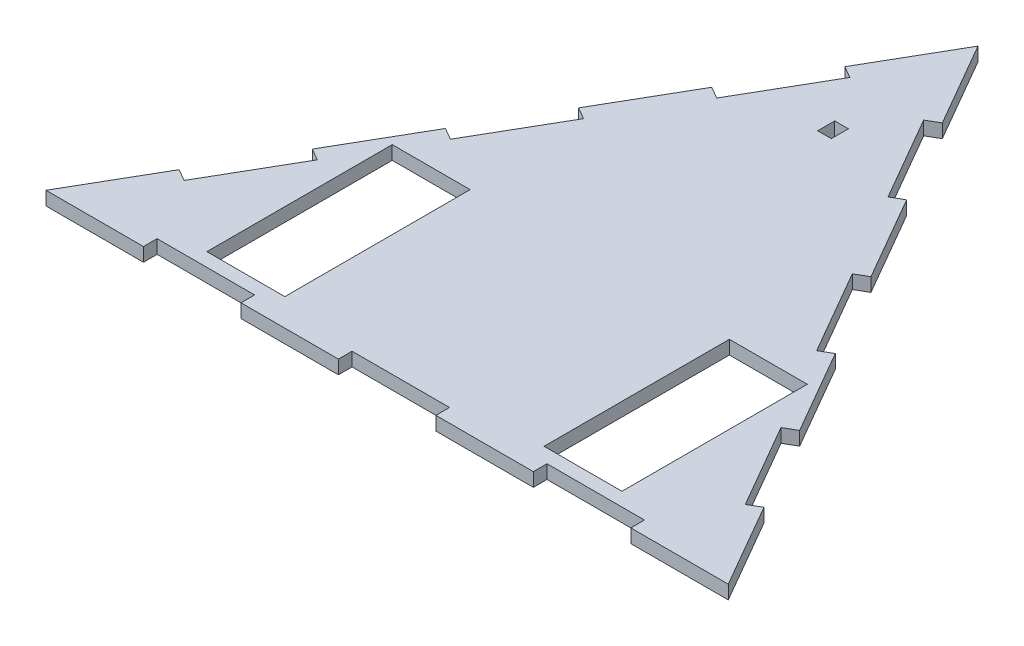
from build123d import *

# Parameters (mm, degrees)
BOSS_EXTRUDE1_DEPTH = 5.08
SKETCH4_W           = 29
SKETCH4_H           = 69
CUT_EXTRUDE1_DEPTH  = 5.08
SKETCH8_W           = 36.285714285
SKETCH8_H           = 5.08
SKETCH8_W_2         = 36.285714286
CUT_EXTRUDE2_DEPTH  = 5.08
SKETCH9_W           = 36.285714285
SKETCH9_H           = 5.08
SKETCH9_W_2         = 36.285714286
CUT_EXTRUDE3_DEPTH  = 5.08
SKETCH10_W          = 36.285714285
SKETCH10_H          = 5.08
SKETCH10_W_2        = 36.285714286
CUT_EXTRUDE4_DEPTH  = 5.08
SKETCH12_W          = 5.08
SKETCH12_H          = 6.35
CUT_EXTRUDE6_DEPTH  = 5.08


with BuildPart() as part:
    # Sketch1 → Boss-Extrude1 (new body)
    with BuildSketch(Plane(origin=(0, 0, 0), x_dir=(1, 0, 0), z_dir=(0, 1, 0))):
        Polygon((0, 0), (-254, 0), (-127, 219.970452561), align=None)
    extrude(amount=BOSS_EXTRUDE1_DEPTH)

    # Sketch4 → Cut-Extrude1 (cut)
    with BuildSketch(Plane(origin=(0, 5.08, 0), x_dir=(1, 0, 0), z_dir=(0, 1, 0))):
        with Locations((-189.76, 44.66)):
            Rectangle(SKETCH4_W, SKETCH4_H)
        with Locations((-64.24, 44.66)):
            Rectangle(SKETCH4_W, SKETCH4_H)
    extrude(amount=-CUT_EXTRUDE1_DEPTH, mode=Mode.SUBTRACT)

    # Sketch8 → Cut-Extrude2 (cut)
    with BuildSketch(Plane(origin=(-190.5, 0, -109.985226281), x_dir=(-0.5, 0, 0.866025404), z_dir=(-0.866025404, 0, -0.5))):
        with Locations((-72.571428572, 2.54)):
            Rectangle(SKETCH8_W, SKETCH8_H)
        with Locations((0, 2.54)):
            Rectangle(SKETCH8_W_2, SKETCH8_H)
        with Locations((72.571428572, 2.54)):
            Rectangle(SKETCH8_W, SKETCH8_H)
    extrude(amount=-CUT_EXTRUDE2_DEPTH, mode=Mode.SUBTRACT)

    # Sketch9 → Cut-Extrude3 (cut)
    with BuildSketch(Plane.XY):
        with Locations((-54.428571428, 2.54)):
            Rectangle(SKETCH9_W, SKETCH9_H)
        with Locations((-127, 2.54)):
            Rectangle(SKETCH9_W_2, SKETCH9_H)
        with Locations((-199.571428572, 2.54)):
            Rectangle(SKETCH9_W, SKETCH9_H)
    extrude(amount=-CUT_EXTRUDE3_DEPTH, mode=Mode.SUBTRACT)

    # Sketch10 → Cut-Extrude4 (cut)
    with BuildSketch(Plane(origin=(0, 0, 0), x_dir=(-0.5, 0, -0.866025404), z_dir=(0.866025404, 0, -0.5))):
        with Locations((54.428571428, 2.54)):
            Rectangle(SKETCH10_W, SKETCH10_H)
        with Locations((127, 2.54)):
            Rectangle(SKETCH10_W_2, SKETCH10_H)
        with Locations((199.571428572, 2.54)):
            Rectangle(SKETCH10_W, SKETCH10_H)
    extrude(amount=-CUT_EXTRUDE4_DEPTH, mode=Mode.SUBTRACT)

    # Sketch12 → Cut-Extrude6 (cut)
    with BuildSketch(Plane(origin=(0, 5.08, 0), x_dir=(1, 0, 0), z_dir=(0, 1, 0))):
        with Locations((-127, 165.995452561)):
            Rectangle(SKETCH12_W, SKETCH12_H)
    extrude(amount=-CUT_EXTRUDE6_DEPTH, mode=Mode.SUBTRACT)


solid = part.part
